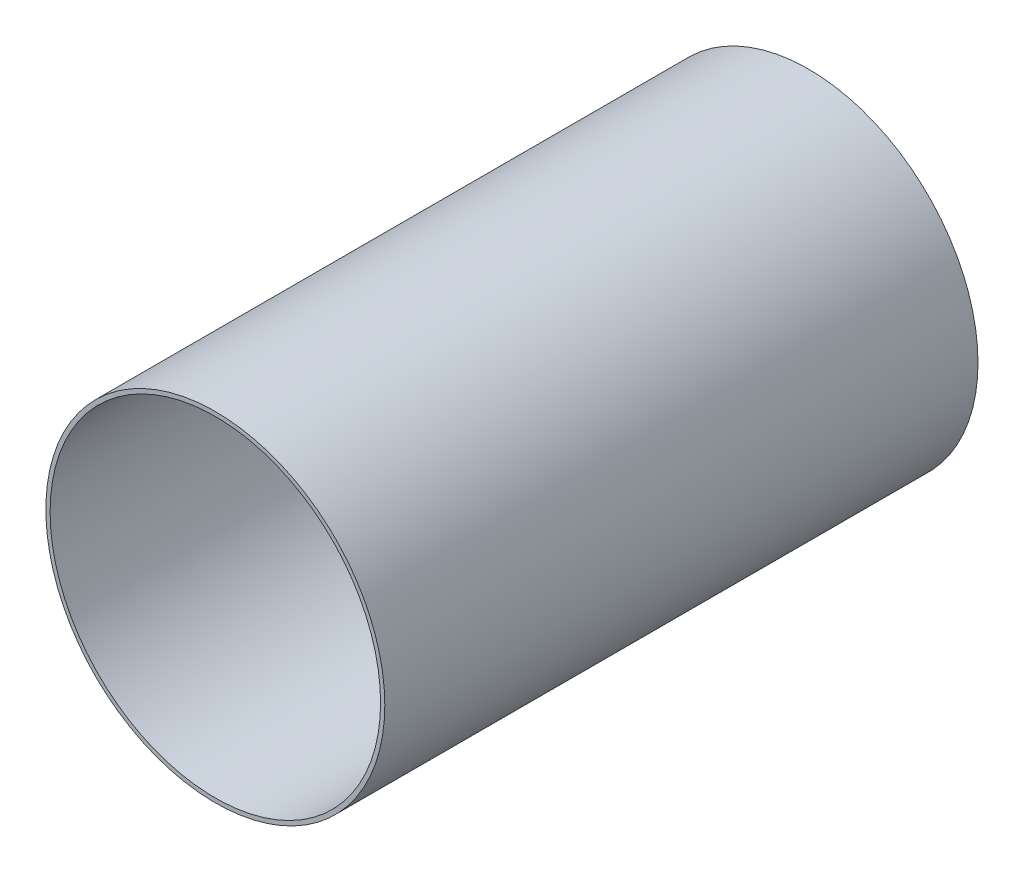
from build123d import *

# Parameters (mm, degrees)
SKETCH1_R           = 20
SKETCH1_R_2         = 19.5
BOSS_EXTRUDE1_DEPTH = 70


with BuildPart() as part:
    # Sketch1 → Boss-Extrude1 (new body)
    with BuildSketch(Plane.XY):
        with Locations((0, 40)):
            Circle(SKETCH1_R)
        with Locations((0, 40)):
            Circle(SKETCH1_R_2, mode=Mode.SUBTRACT)
    extrude(amount=BOSS_EXTRUDE1_DEPTH)


solid = part.part
